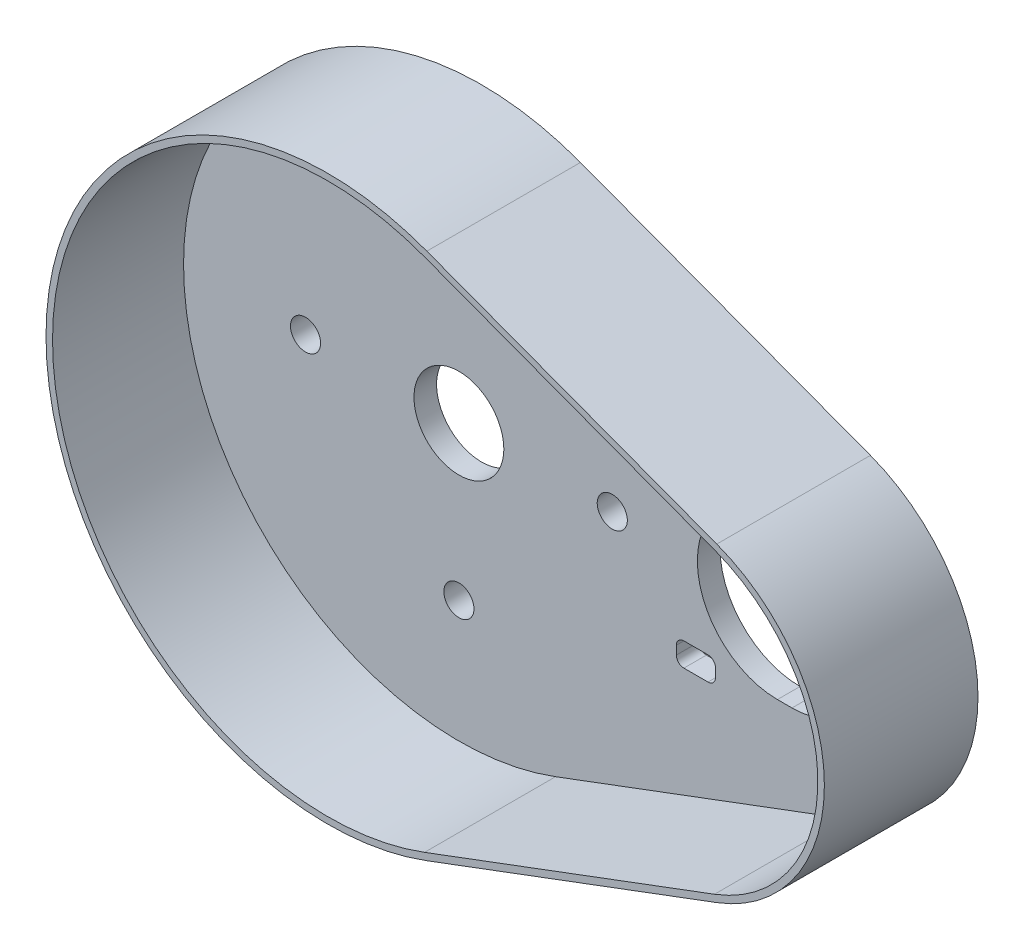
from build123d import *

# Parameters (mm, degrees)
SKETCH1_R           = 3
SKETCH1_W           = 7.8
SKETCH1_H           = 4.7
SKETCH1_R_2         = 8.95
BOSS_EXTRUDE1_DEPTH = 30.6
CUT_EXTRUDE1_DEPTH  = 26.1
FILETE1_R           = 1.5


with BuildPart() as part:
    # Sketch1 → Boss-Extrude1 (new body)
    with BuildSketch(Plane.XY):
        with BuildLine():
            ThreePointArc((77.466015174, -30.925650144), (98.9, 0), (77.466015174, 30.925650144))
            Line((77.466015174, 30.925650144), (19.70985088, 52.577031851))
            ThreePointArc((19.70985088, 52.577031851), (-56.15, 0), (19.70985088, -52.577031851))
            Line((19.70985088, -52.577031851), (77.466015174, -30.925650144))
        make_face()
        with BuildLine():
            Line((63.45, 15.95), (66.35, 15.95))
            ThreePointArc((66.35, 15.95), (82.3, 0), (66.35, -15.95))
            Line((66.35, -15.95), (63.45, -15.95))
            ThreePointArc((63.45, -15.95), (47.5, 0), (63.45, 15.95))
        make_face(mode=Mode.SUBTRACT)
        with Locations((30.55, 0)):
            Circle(SKETCH1_R, mode=Mode.SUBTRACT)
        with Locations((82.211647497, -17.5)):
            Rectangle(SKETCH1_W, SKETCH1_H, mode=Mode.SUBTRACT)
        with Locations((82.211647497, 17.5)):
            Rectangle(SKETCH1_W, SKETCH1_H, mode=Mode.SUBTRACT)
        with Locations((47.211647497, 17.5)):
            Rectangle(SKETCH1_W, SKETCH1_H, mode=Mode.SUBTRACT)
        with Locations((47.211647497, -17.5)):
            Rectangle(SKETCH1_W, SKETCH1_H, mode=Mode.SUBTRACT)
        Circle(SKETCH1_R_2, mode=Mode.SUBTRACT)
        with Locations((0, 30.55)):
            Circle(SKETCH1_R, mode=Mode.SUBTRACT)
        with Locations((0, -30.55)):
            Circle(SKETCH1_R, mode=Mode.SUBTRACT)
        with Locations((-30.55, 0)):
            Circle(SKETCH1_R, mode=Mode.SUBTRACT)
    extrude(amount=BOSS_EXTRUDE1_DEPTH)

    # Sketch2 → Cut-Extrude1 (cut)
    with BuildSketch(Plane.XY.offset(30.6)):
        with BuildLine():
            Line((77.009687371, 29.70837247), (19.253523077, 51.359754177))
            ThreePointArc((19.253523077, 51.359754177), (-54.85, 0), (19.253523077, -51.359754177))
            Line((19.253523077, -51.359754177), (77.009687371, -29.70837247))
            ThreePointArc((77.009687371, -29.70837247), (97.6, 0), (77.009687371, 29.70837247))
        make_face()
    extrude(amount=-CUT_EXTRUDE1_DEPTH, mode=Mode.SUBTRACT)

    # Filete1
    filete1_edges = [part.edges().sort_by_distance(p)[0] for p in [
        (51.111647497, -19.85, 2.25),
        (51.111647497, -15.15, 2.25),
        (86.111647497, -19.85, 2.25),
        (86.111647497, -15.15, 2.25),
        (51.111647497, 15.15, 2.25),
        (51.111647497, 19.85, 2.25),
        (43.311647497, -15.15, 2.25),
        (43.311647497, -19.85, 2.25),
        (78.311647497, -15.15, 2.25),
        (78.311647497, -19.85, 2.25),
        (86.111647497, 15.15, 2.25),
        (86.111647497, 19.85, 2.25),
        (78.311647497, 19.85, 2.25),
        (78.311647497, 15.15, 2.25),
        (43.311647497, 19.85, 2.25),
        (43.311647497, 15.15, 2.25),
    ]]
    fillet(filete1_edges, radius=FILETE1_R)


solid = part.part
